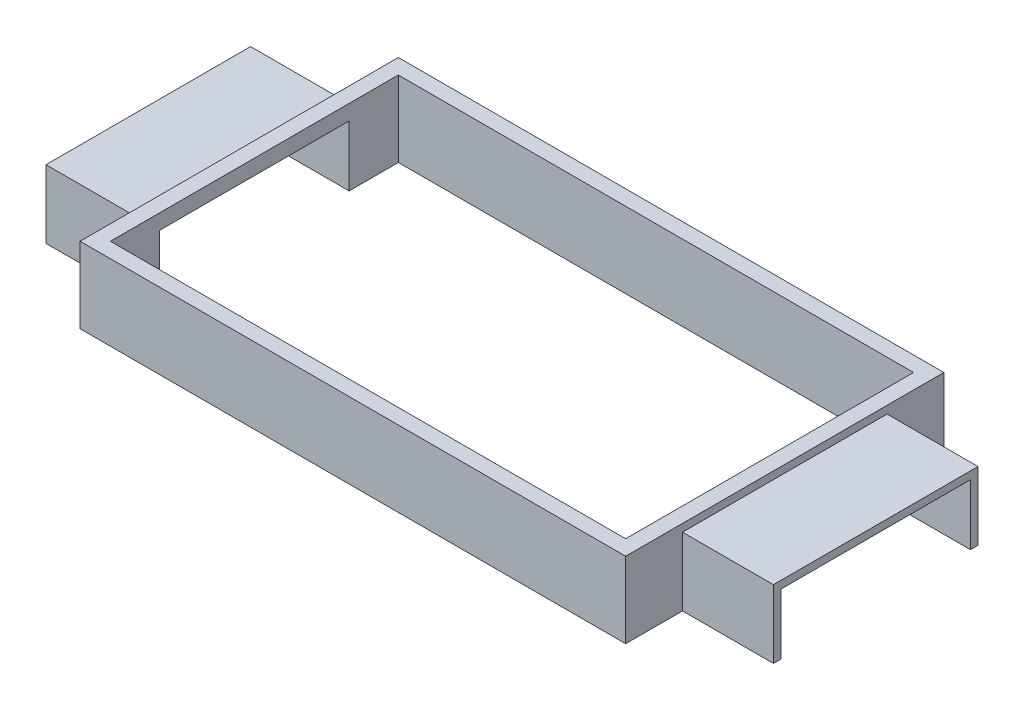
from build123d import *

# Parameters (mm, degrees)
SKETCH_1_W          = 72
SKETCH_1_H          = 42
SKETCH_1_W_2        = 68
SKETCH_1_H_2        = 38
EXTRUDE_1_DEPTH     = 10
SKETCH_2_W          = 25
SKETCH_2_H          = 8
CUT_EXTRUDE_1_DEPTH = 81
EXTRUDE_4_DEPTH     = 12
EXTRUDE_5_DEPTH     = 12


with BuildPart() as part:
    # 草圖1 → 填料-伸長1 (new body)
    with BuildSketch(Plane(origin=(0, 0, 0), x_dir=(1, 0, 0), z_dir=(0, 1, 0))):
        Rectangle(SKETCH_1_W, SKETCH_1_H)
        Rectangle(SKETCH_1_W_2, SKETCH_1_H_2, mode=Mode.SUBTRACT)
    extrude(amount=EXTRUDE_1_DEPTH)

    # 草圖2 → 除料-伸長1 (cut)
    with BuildSketch(Plane(origin=(36, 0, 0), x_dir=(0, 0, -1), z_dir=(1, 0, 0))):
        with Locations((0, 4)):
            Rectangle(SKETCH_2_W, SKETCH_2_H)
    extrude(amount=-CUT_EXTRUDE_1_DEPTH, mode=Mode.SUBTRACT)

    # 草圖7 → 填料-伸長4 (add)
    with BuildSketch(Plane(origin=(36, 0, 0), x_dir=(0, 0, -1), z_dir=(1, 0, 0))):
        Polygon((12.5, 0), (12.5, 8), (-12.5, 8), (-12.5, 0), (-13.5, 0), (-13.5, 9), (13.5, 9), (13.5, 0), align=None)
    extrude(amount=EXTRUDE_4_DEPTH)

    # 草圖9 → 填料-伸長5 (add)
    with BuildSketch(Plane.ZY.offset(36)):
        Polygon((12.5, 8), (12.5, 0), (13.5, 0), (13.5, 9), (-13.5, 9), (-13.5, 0), (-12.5, 0), (-12.5, 8), align=None)
    extrude(amount=EXTRUDE_5_DEPTH)


solid = part.part
